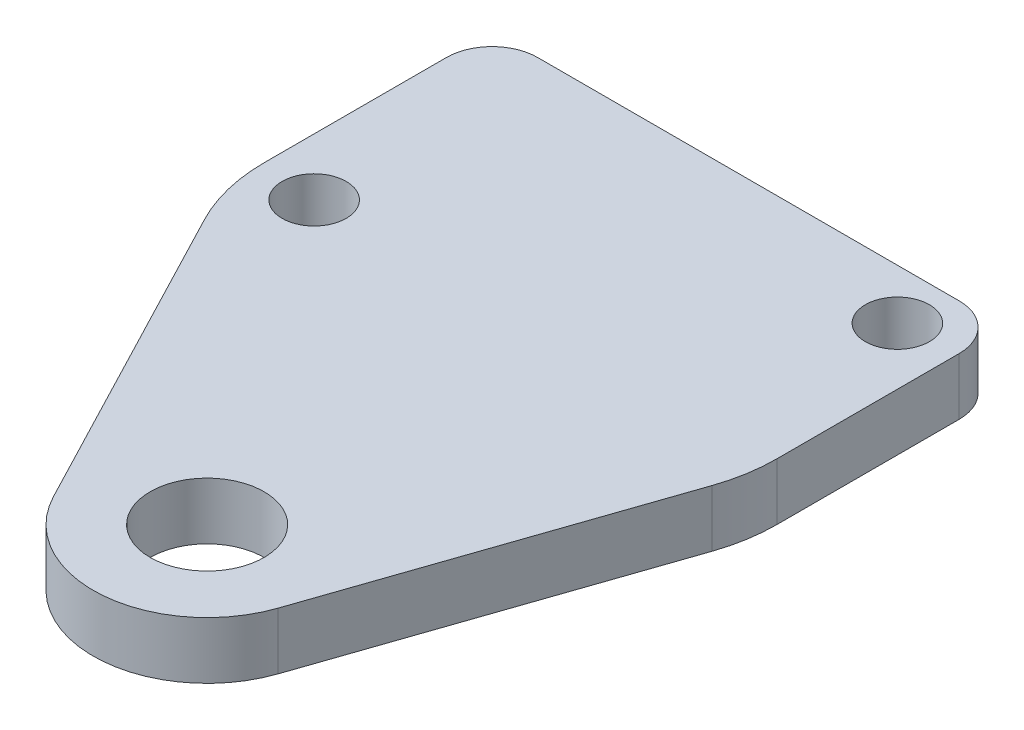
from build123d import *

# Parameters (mm, degrees)
SKETCH1_R           = 3.175
BOSS_EXTRUDE1_DEPTH = 3.175
SKETCH2_R           = 1.7859375
CUT_EXTRUDE1_DEPTH  = 4.175
FILLET1_R           = 2.54


with BuildPart() as part:
    # Sketch1 → Boss-Extrude1 (new body)
    with BuildSketch(Plane(origin=(0, 0, 0), x_dir=(1, 0, 0), z_dir=(0, 1, 0))):
        with BuildLine():
            Line((-14.79629089, 14.647069703), (-5.630860593, -2.935286864))
            ThreePointArc((-5.630860593, -2.935286864), (0.476542645, -6.332093422), (6.006756757, -2.059459459))
            Line((6.006756757, -2.059459459), (12.185135135, 15.960810811))
            ThreePointArc((12.185135135, 15.960810811), (12.570402125, 17.484099646), (12.7, 19.05))
            Line((12.7, 19.05), (12.7, 31.75))
            Line((12.7, 31.75), (-15.875, 31.75))
            Line((-15.875, 31.75), (-15.875, 19.05))
            ThreePointArc((-15.875, 19.05), (-15.601393023, 16.783427227), (-14.79629089, 14.647069703))
        make_face()
        Circle(SKETCH1_R, mode=Mode.SUBTRACT)
    extrude(amount=BOSS_EXTRUDE1_DEPTH)

    # Sketch2 → Cut-Extrude1 (cut, through all)
    with BuildSketch(Plane(origin=(0, 3.175, 0), x_dir=(1, 0, 0), z_dir=(0, 1, 0))):
        with Locations((-12.6875, 18.65)):
            Circle(SKETCH2_R)
        with Locations((9.5125, 28.95)):
            Circle(SKETCH2_R)
    extrude(amount=-CUT_EXTRUDE1_DEPTH, mode=Mode.SUBTRACT)

    # Fillet1
    fillet1_edges = [part.edges().sort_by_distance(p)[0] for p in [
        (-15.875, 1.5875, -31.75),
        (12.7, 1.5875, -31.75),
    ]]
    fillet(fillet1_edges, radius=FILLET1_R)


solid = part.part
